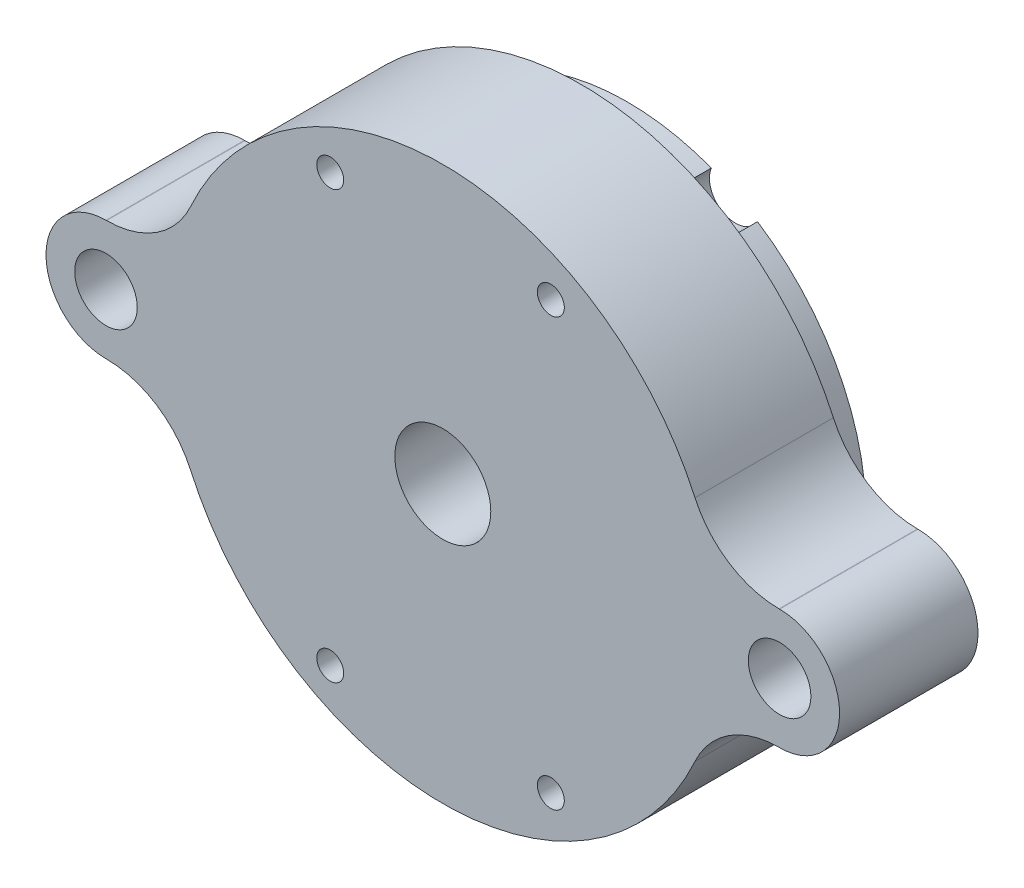
from build123d import *

# Parameters (mm, degrees)
SKETCH1_R                                       = 3.302
BOSS_EXTRUDE1_DEPTH                             = 6.35
SKETCH2_R                                       = 16.4211
BOSS_EXTRUDE3_DEPTH                             = 6.35
BOSS_EXTRUDE3_DEPTH_BACK                        = 3.175
F_6_CLEARANCE_HOLE1_D                           = 4.3053
F_6_CLEARANCE_HOLE1_DEPTH                       = 9.525
F_6_PLASTIC_INSERT_AT_2_COUNT                   = 2
F_6_PLASTIC_INSERT_AT_2_PITCH                   = 46.355
BOSS_EXTRUDE4_REACH                             = 14.7
SKETCH22_R                                      = 16.4211
SKETCH22_R_2                                    = 3.302
CBORE_FOR_0_PAN_HEAD_MACHINE_SCREW1_D           = 1.8542
CBORE_FOR_0_PAN_HEAD_MACHINE_SCREW1_CBORE_D     = 3.57124
CBORE_FOR_0_PAN_HEAD_MACHINE_SCREW1_CBORE_DEPTH = 6.35


with BuildPart() as part:
    # Sketch1 → Boss-Extrude1 (new body)
    with BuildSketch(Plane.XY):
        with BuildLine():
            ThreePointArc((16.170566439, -2.8575), (16.4211, 0), (16.170566439, 2.8575))
            ThreePointArc((16.170566439, 2.8575), (0, 16.4211), (-16.170566439, 2.8575))
            ThreePointArc((-16.170566439, 2.8575), (-16.4211, 0), (-16.170566439, -2.8575))
            ThreePointArc((-16.170566439, -2.8575), (0, -16.4211), (16.170566439, -2.8575))
        make_face()
        Circle(SKETCH1_R, mode=Mode.SUBTRACT)
    extrude(amount=BOSS_EXTRUDE1_DEPTH)

    # Sketch2 → Boss-Extrude3 (add, two sides)
    with BuildSketch(Plane.XY.offset(6.35)) as boss_extrude3_sk:
        with BuildLine():
            Line((23.1775, 4.1275), (23.138323054, 4.1275))
            ThreePointArc((23.138323054, 4.1275), (19.696705066, 5.14104372), (17.35374229, 7.858125))
            ThreePointArc((17.35374229, 7.858125), (0, 19.05), (-17.35374229, 7.858125))
            ThreePointArc((-17.35374229, 7.858125), (-19.696705066, 5.14104372), (-23.138323054, 4.1275))
            Line((-23.138323054, 4.1275), (-23.1775, 4.1275))
            ThreePointArc((-23.1775, 4.1275), (-27.305, 0), (-23.1775, -4.1275))
            Line((-23.1775, -4.1275), (-23.138323054, -4.1275))
            ThreePointArc((-23.138323054, -4.1275), (-19.696705066, -5.14104372), (-17.35374229, -7.858125))
            ThreePointArc((-17.35374229, -7.858125), (0, -19.05), (17.35374229, -7.858125))
            ThreePointArc((17.35374229, -7.858125), (19.696705066, -5.14104372), (23.138323054, -4.1275))
            Line((23.138323054, -4.1275), (23.1775, -4.1275))
            ThreePointArc((23.1775, -4.1275), (27.305, 0), (23.1775, 4.1275))
        make_face()
        Circle(SKETCH2_R, mode=Mode.SUBTRACT)
    extrude(amount=BOSS_EXTRUDE3_DEPTH)
    extrude(boss_extrude3_sk.sketch, amount=-BOSS_EXTRUDE3_DEPTH_BACK)

    # #6 Clearance Hole1
    with Locations(Plane(origin=(-22.699598292, 0.104385938, 3.175), x_dir=(-1, 0, 0), z_dir=(0, 0, -1))):
        with Locations((-45.877098292, -0.104385938), (0.477901708, -0.104385938)):
            Hole(F_6_CLEARANCE_HOLE1_D / 2, depth=F_6_CLEARANCE_HOLE1_DEPTH)

    # Sketch5 → #6 Plastic Insert (revolve, cut)
    with BuildSketch(Plane(origin=(23.1775, 0, 3.175), x_dir=(0, 1, 0), z_dir=(1, 0, 0))):
        Polygon((0, 0), (0, 3.81), (2.5273, 3.81), (2.6543, 0), align=None)
    f_6_plastic_insert = revolve(axis=Axis((23.1775, 0, 113.175), (0, 0, -1)), mode=Mode.SUBTRACT)

    # #6 Plastic Insert at 2: #6 Plastic Insert ×2
    with Locations(*[(-i * F_6_PLASTIC_INSERT_AT_2_PITCH, 0, 0) for i in range(1, F_6_PLASTIC_INSERT_AT_2_COUNT)]):
        add(f_6_plastic_insert, mode=Mode.SUBTRACT)

    # Sketch22 → Boss-Extrude4 (add, up to next)
    with BuildSketch(Plane.XY.offset(12.7), mode=Mode.PRIVATE) as boss_extrude4_sk1:
        Circle(SKETCH22_R)
        Circle(SKETCH22_R_2, mode=Mode.SUBTRACT)
    boss_extrude4_tool1 = extrude(boss_extrude4_sk1.sketch, amount=-BOSS_EXTRUDE4_REACH, mode=Mode.PRIVATE) - part.part
    add(boss_extrude4_tool1.solids().sort_by_distance((-15.956641, 0, 12.7))[0])

    # CBORE for #0 Pan Head Machine Screw1 (through all)
    with Locations(Plane(origin=(0, 0, 0), x_dir=(-1, 0, 0), z_dir=(0, 0, -1))):
        with Locations((-7.435045578, 14.69458661), (7.747421379, 14.69458661), (7.747421379, -14.69458661), (-7.435045578, -14.69458661)):
            CounterBoreHole(CBORE_FOR_0_PAN_HEAD_MACHINE_SCREW1_D / 2, CBORE_FOR_0_PAN_HEAD_MACHINE_SCREW1_CBORE_D / 2, CBORE_FOR_0_PAN_HEAD_MACHINE_SCREW1_CBORE_DEPTH)


solid = part.part
